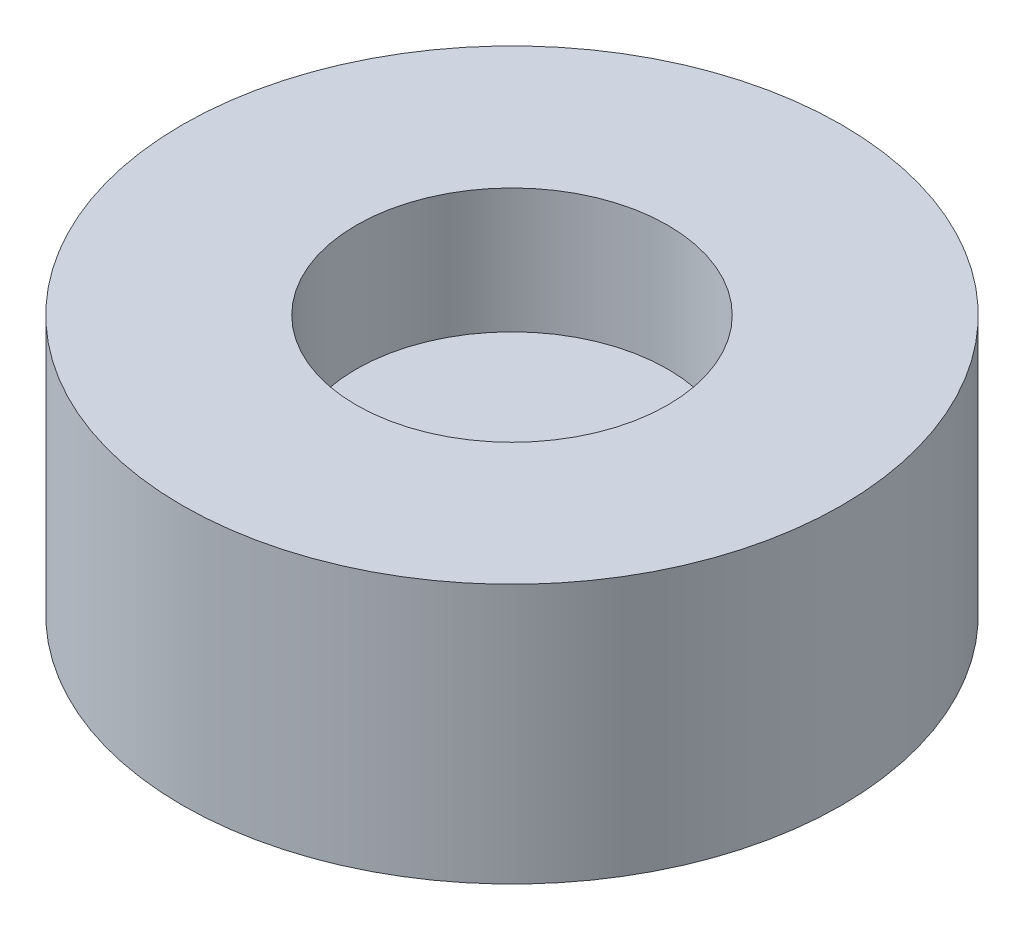
from build123d import *

# Parameters (mm, degrees)
SKETCH1_R           = 6.35
BOSS_EXTRUDE1_DEPTH = 5
SKETCH2_R           = 3
CUT_EXTRUDE1_DEPTH  = 2.4


with BuildPart() as part:
    # Sketch1 → Boss-Extrude1 (new body)
    with BuildSketch(Plane(origin=(0, 0, 0), x_dir=(1, 0, 0), z_dir=(0, 1, 0))):
        Circle(SKETCH1_R)
    extrude(amount=BOSS_EXTRUDE1_DEPTH)

    # Sketch2 → Cut-Extrude1 (cut)
    with BuildSketch(Plane(origin=(0, 5, 0), x_dir=(1, 0, 0), z_dir=(0, 1, 0))):
        Circle(SKETCH2_R)
    extrude(amount=-CUT_EXTRUDE1_DEPTH, mode=Mode.SUBTRACT)


solid = part.part
